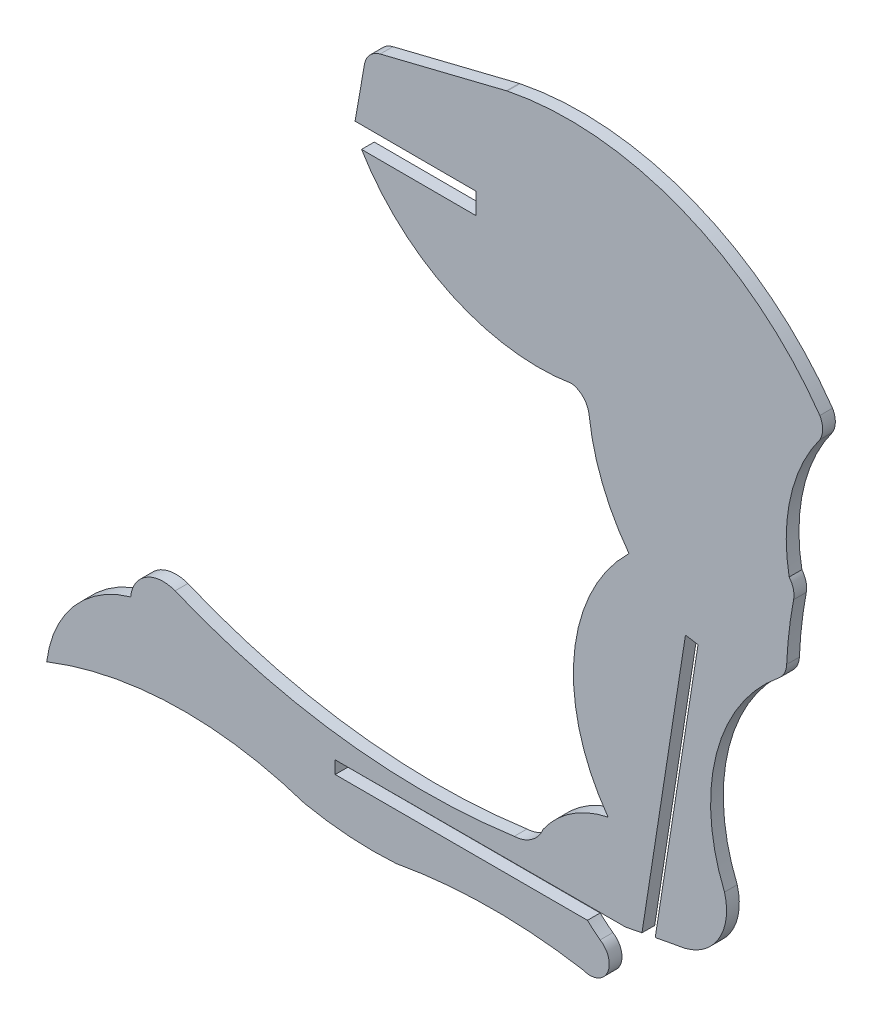
from build123d import *

# Parameters (mm, degrees)
BOSS_EXTRUDE1_DEPTH = 1.524


with BuildPart() as part:
    # Sketch1 → Boss-Extrude1 (new body)
    with BuildSketch(Plane.XY):
        with BuildLine():
            Line((216.672701746, -0.007446462), (216.672701746, -2.547446462))
            Line((216.672701746, -2.547446462), (202.922883793, -2.527561419))
            ThreePointArc((202.922883793, -2.527561419), (213.740389033, -12.255488314), (228.152940708, -14.237743463))
            ThreePointArc((228.152940708, -14.237743463), (229.539309592, -15.004139991), (230.201920973, -16.443003598))
            ThreePointArc((230.201920973, -16.443003598), (231.794065838, -22.769182164), (234.983138477, -28.459988454))
            ThreePointArc((234.983138477, -28.459988454), (228.404400606, -42.301387702), (232.479424339, -57.074955542))
            ThreePointArc((232.479424339, -57.074955542), (228.088258842, -58.913193865), (224.685678773, -62.242443545))
            ThreePointArc((224.685678773, -62.242443545), (223.318434752, -63.974353777), (221.232380668, -64.693553069))
            ThreePointArc((221.232380668, -64.693553069), (200.556241101, -64.829244423), (180.56810467, -59.538161211))
            ThreePointArc((180.56810467, -59.538161211), (177.088182276, -59.862533625), (175.243626571, -62.831151415))
            ThreePointArc((175.243626571, -62.831151415), (168.436022627, -67.194555572), (165.179908551, -74.595939794))
            ThreePointArc((165.179908551, -74.595939794), (180.56810467, -71.491688256), (196.088301261, -73.848901695))
            ThreePointArc((196.088301261, -73.848901695), (201.561550117, -74.595878453), (207.085536659, -74.595939794))
            ThreePointArc((207.085536659, -74.595939794), (218.25265241, -73.536219791), (229.434140266, -74.431658236))
            ThreePointArc((229.434140266, -74.431658236), (232.368160186, -73.324137561), (231.528773962, -70.302464895))
            ThreePointArc((231.528773962, -70.302464895), (230.749723909, -69.684443769), (230.004496974, -69.026032112))
            Line((230.004496974, -69.026032112), (199.761798891, -69.011393679))
            Line((199.761798891, -69.011393679), (199.761798891, -67.487393679))
            Line((199.761798891, -67.487393679), (234.591320158, -67.44538381))
            ThreePointArc((234.591320158, -67.44538381), (235.566450517, -67.25102819), (236.542114519, -67.059369434))
            Line((236.542114519, -67.059369434), (241.754501837, -33.540074699))
            Line((241.754501837, -33.540074699), (243.260404343, -33.774248693))
            Line((243.260404343, -33.774248693), (238.132067507, -66.75304007))
            ThreePointArc((238.132067507, -66.75304007), (239.89605254, -66.421852491), (241.661668499, -66.099472755))
            ThreePointArc((241.661668499, -66.099472755), (245.789044159, -63.002771973), (246.435787058, -57.883542618))
            ThreePointArc((246.435787058, -57.883542618), (245.449591498, -44.052865168), (252.944866234, -32.387485746))
            ThreePointArc((252.944866234, -32.387485746), (253.618048182, -31.554800294), (253.888271711, -30.518693039))
            ThreePointArc((253.888271711, -30.518693039), (254.1727268, -26.934998032), (254.717509197, -23.381549463))
            ThreePointArc((254.717509197, -23.381549463), (254.684120067, -22.279090661), (254.186569515, -21.294726048))
            ThreePointArc((254.186569515, -21.294726048), (254.359804188, -12.854167351), (257.874930037, -5.178430798))
            ThreePointArc((257.874930037, -5.178430798), (258.196394426, -3.928637169), (257.862228141, -2.682179643))
            ThreePointArc((257.862228141, -2.682179643), (241.364921289, 10.401189736), (220.392134228, 12.266100085))
            ThreePointArc((220.392134228, 12.266100085), (220.341626443, 12.255208572), (220.291350651, 12.243291934))
            Line((220.291350651, 12.243291934), (205.161370791, 8.494168867))
            ThreePointArc((205.161370791, 8.494168867), (203.913862316, 7.760159754), (203.269847057, 6.463899318))
            Line((203.269847057, 6.463899318), (202.1481549, 0.013558997))
            Line((202.1481549, 0.013558997), (216.672701746, -0.007446462))
        make_face()
    extrude(amount=BOSS_EXTRUDE1_DEPTH)


solid = part.part
